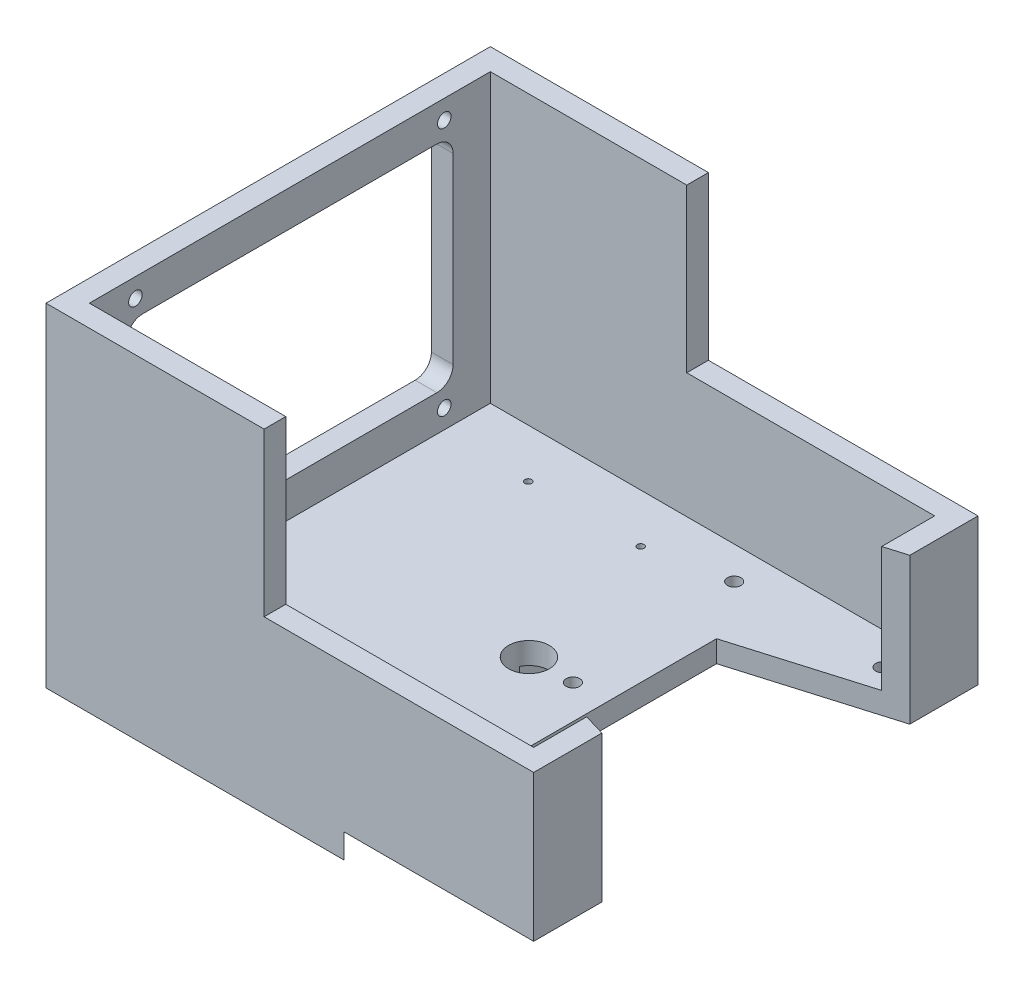
from build123d import *

# Parameters (mm, degrees)
BOSS_EXTRUDE1_DEPTH = 8
BOSS_EXTRUDE2_DEPTH = 9
BOSS_EXTRUDE3_DEPTH = 106
CUT_EXTRUDE1_REACH  = 163.431
SKETCH4_R           = 2.5
SKETCH4_R_2         = 7.5
CUT_EXTRUDE2_REACH  = 163.431
SKETCH5_R           = 1.25
SKETCH7_W           = 99.5
SKETCH7_H           = 60
CUT_EXTRUDE3_DEPTH  = 220.070764823
CUT_EXTRUDE4_REACH  = 224.045


with BuildPart() as part:
    # Sketch1 → Boss-Extrude1 (new body)
    with BuildSketch(Plane(origin=(0, 0, 0), x_dir=(1, 0, 0), z_dir=(0, 1, 0))):
        Polygon((35, 40.5), (90, 56.816666667), (90, 82), (-90, 82), (-90, -82), (90, -82), (90, -56.816666667), (35, -40.5), align=None)
    extrude(amount=BOSS_EXTRUDE1_DEPTH)

    # Sketch2 → Boss-Extrude2 (add)
    with BuildSketch(Plane.XZ):
        with BuildLine():
            ThreePointArc((-0.5, 61.5), (5.504310986, 75.995689014), (20, 82))
            Line((20, 82), (-90, 82))
            Line((-90, 82), (-90, -82))
            Line((-90, -82), (20, -82))
            ThreePointArc((20, -82), (5.504310986, -75.995689014), (-0.5, -61.5))
            Line((-0.5, -61.5), (-0.5, 61.5))
        make_face()
    extrude(amount=BOSS_EXTRUDE2_DEPTH)

    # Sketch3 → Boss-Extrude3 (add)
    with BuildSketch(Plane(origin=(0, 8, 0), x_dir=(1, 0, 0), z_dir=(0, 1, 0))):
        Polygon((90, 82), (-90, 82), (-90, -82), (90, -82), (90, -56.816666667), (82, -54.443333333), (82, -62.787955021), (82, -74), (-82, -74), (-82, 74), (82, 74), (82, 62.787955021), (82, 54.443333333), (90, 56.816666667), align=None)
    extrude(amount=BOSS_EXTRUDE3_DEPTH)

    # Sketch4 → Cut-Extrude1 (cut, up to next)
    with BuildSketch(Plane(origin=(0, 8, 0), x_dir=(1, 0, 0), z_dir=(0, 1, 0)), mode=Mode.PRIVATE) as cut_extrude1_sk1:
        with Locations(Location((74.76, 62, 0), (0, 0, 270))):
            Circle(SKETCH4_R)
    cut_extrude1_tool1 = extrude(cut_extrude1_sk1.sketch, amount=-CUT_EXTRUDE1_REACH, mode=Mode.PRIVATE) & part.part
    # Sketch4 → Cut-Extrude1 (cut, up to next)
    with BuildSketch(Plane(origin=(0, 8, 0), x_dir=(1, 0, 0), z_dir=(0, 1, 0)), mode=Mode.PRIVATE) as cut_extrude1_sk2:
        with Locations(Location((6.25, 0, 0), (0, 0, 270))):
            Circle(SKETCH4_R_2)
    cut_extrude1_tool2 = extrude(cut_extrude1_sk2.sketch, amount=-CUT_EXTRUDE1_REACH, mode=Mode.PRIVATE) & part.part
    # Sketch4 → Cut-Extrude1 (cut, up to next)
    with BuildSketch(Plane(origin=(0, 8, 0), x_dir=(1, 0, 0), z_dir=(0, 1, 0)), mode=Mode.PRIVATE) as cut_extrude1_sk3:
        with Locations(Location((22.5, 0, 0), (0, 0, 270))):
            Circle(SKETCH4_R)
    cut_extrude1_tool3 = extrude(cut_extrude1_sk3.sketch, amount=-CUT_EXTRUDE1_REACH, mode=Mode.PRIVATE) & part.part
    # Sketch4 → Cut-Extrude1 (cut, up to next)
    with BuildSketch(Plane(origin=(0, 8, 0), x_dir=(1, 0, 0), z_dir=(0, 1, 0)), mode=Mode.PRIVATE) as cut_extrude1_sk4:
        with Locations(Location((20, 62, 0), (0, 0, 270))):
            Circle(SKETCH4_R)
    cut_extrude1_tool4 = extrude(cut_extrude1_sk4.sketch, amount=-CUT_EXTRUDE1_REACH, mode=Mode.PRIVATE) & part.part
    # Sketch4 → Cut-Extrude1 (cut, up to next)
    with BuildSketch(Plane(origin=(0, 8, 0), x_dir=(1, 0, 0), z_dir=(0, 1, 0)), mode=Mode.PRIVATE) as cut_extrude1_sk5:
        with Locations(Location((20, -62, 0), (0, 0, 270))):
            Circle(SKETCH4_R)
    cut_extrude1_tool5 = extrude(cut_extrude1_sk5.sketch, amount=-CUT_EXTRUDE1_REACH, mode=Mode.PRIVATE) & part.part
    # Sketch4 → Cut-Extrude1 (cut, up to next)
    with BuildSketch(Plane(origin=(0, 8, 0), x_dir=(1, 0, 0), z_dir=(0, 1, 0)), mode=Mode.PRIVATE) as cut_extrude1_sk6:
        with Locations(Location((74.76, -62, 0), (0, 0, 270))):
            Circle(SKETCH4_R)
    cut_extrude1_tool6 = extrude(cut_extrude1_sk6.sketch, amount=-CUT_EXTRUDE1_REACH, mode=Mode.PRIVATE) & part.part
    add(cut_extrude1_tool1.solids().sort_by_distance((74.76, 8, -62))[0], mode=Mode.SUBTRACT)
    add(cut_extrude1_tool2.solids().sort_by_distance((6.25, 8, 0))[0], mode=Mode.SUBTRACT)
    add(cut_extrude1_tool3.solids().sort_by_distance((22.5, 8, 0))[0], mode=Mode.SUBTRACT)
    add(cut_extrude1_tool4.solids().sort_by_distance((20, 8, -62))[0], mode=Mode.SUBTRACT)
    add(cut_extrude1_tool5.solids().sort_by_distance((20, 8, 62))[0], mode=Mode.SUBTRACT)
    add(cut_extrude1_tool6.solids().sort_by_distance((74.76, 8, 62))[0], mode=Mode.SUBTRACT)

    # Sketch5 → Cut-Extrude2 (cut, up to next)
    with BuildSketch(Plane(origin=(0, 8, 0), x_dir=(1, 0, 0), z_dir=(0, 1, 0)), mode=Mode.PRIVATE) as cut_extrude2_sk1:
        with Locations(Location((-50, 56, 0), (0, 0, 270))):
            Circle(SKETCH5_R)
    cut_extrude2_tool1 = extrude(cut_extrude2_sk1.sketch, amount=-CUT_EXTRUDE2_REACH, mode=Mode.PRIVATE) & part.part
    # Sketch5 → Cut-Extrude2 (cut, up to next)
    with BuildSketch(Plane(origin=(0, 8, 0), x_dir=(1, 0, 0), z_dir=(0, 1, 0)), mode=Mode.PRIVATE) as cut_extrude2_sk2:
        with Locations(Location((-8.5, 56, 0), (0, 0, 90))):
            Circle(SKETCH5_R)
    cut_extrude2_tool2 = extrude(cut_extrude2_sk2.sketch, amount=-CUT_EXTRUDE2_REACH, mode=Mode.PRIVATE) & part.part
    # Sketch5 → Cut-Extrude2 (cut, up to next)
    with BuildSketch(Plane(origin=(0, 8, 0), x_dir=(1, 0, 0), z_dir=(0, 1, 0)), mode=Mode.PRIVATE) as cut_extrude2_sk3:
        with Locations(Location((-8.5, -56, 0), (0, 0, 270))):
            Circle(SKETCH5_R)
    cut_extrude2_tool3 = extrude(cut_extrude2_sk3.sketch, amount=-CUT_EXTRUDE2_REACH, mode=Mode.PRIVATE) & part.part
    # Sketch5 → Cut-Extrude2 (cut, up to next)
    with BuildSketch(Plane(origin=(0, 8, 0), x_dir=(1, 0, 0), z_dir=(0, 1, 0)), mode=Mode.PRIVATE) as cut_extrude2_sk4:
        with Locations(Location((-50, -56, 0), (0, 0, 90))):
            Circle(SKETCH5_R)
    cut_extrude2_tool4 = extrude(cut_extrude2_sk4.sketch, amount=-CUT_EXTRUDE2_REACH, mode=Mode.PRIVATE) & part.part
    add(cut_extrude2_tool1.solids().sort_by_distance((-50, 8, -56))[0], mode=Mode.SUBTRACT)
    add(cut_extrude2_tool2.solids().sort_by_distance((-8.5, 8, -56))[0], mode=Mode.SUBTRACT)
    add(cut_extrude2_tool3.solids().sort_by_distance((-8.5, 8, 56))[0], mode=Mode.SUBTRACT)
    add(cut_extrude2_tool4.solids().sort_by_distance((-50, 8, 56))[0], mode=Mode.SUBTRACT)

    # Sketch7 → Cut-Extrude3 (cut, through all)
    with BuildSketch(Plane.XY.offset(82)):
        with Locations((40.25, 84)):
            Rectangle(SKETCH7_W, SKETCH7_H)
    extrude(amount=-CUT_EXTRUDE3_DEPTH, mode=Mode.SUBTRACT)

    # Sketch8 → Cut-Extrude4 (cut, up to next)
    with BuildSketch(Plane(origin=(-82, 0, 0), x_dir=(0, 0, -1), z_dir=(1, 0, 0)), mode=Mode.PRIVATE) as cut_extrude4_sk1:
        with BuildLine():
            Line((-57, 104.5), (-57, 107))
            Line((-57, 107), (-54.5, 107))
            ThreePointArc((-54.5, 107), (-58.767766953, 108.767766953), (-57, 104.5))
        make_face()
    cut_extrude4_tool1 = extrude(cut_extrude4_sk1.sketch, amount=-CUT_EXTRUDE4_REACH, mode=Mode.PRIVATE) & part.part
    # Sketch8 → Cut-Extrude4 (cut, up to next)
    with BuildSketch(Plane(origin=(-82, 0, 0), x_dir=(0, 0, -1), z_dir=(1, 0, 0)), mode=Mode.PRIVATE) as cut_extrude4_sk2:
        with BuildLine():
            Line((-54.5, 107), (-57, 107))
            Line((-57, 107), (-57, 104.5))
            ThreePointArc((-57, 104.5), (-55.232233047, 105.232233047), (-54.5, 107))
        make_face()
    cut_extrude4_tool2 = extrude(cut_extrude4_sk2.sketch, amount=-CUT_EXTRUDE4_REACH, mode=Mode.PRIVATE) & part.part
    # Sketch8 → Cut-Extrude4 (cut, up to next)
    with BuildSketch(Plane(origin=(-82, 0, 0), x_dir=(0, 0, -1), z_dir=(1, 0, 0)), mode=Mode.PRIVATE) as cut_extrude4_sk3:
        with BuildLine():
            Line((-57, 104.5), (-57, 107))
            Line((-57, 107), (-54.5, 107))
            ThreePointArc((-54.5, 107), (-58.767766953, 108.767766953), (-57, 104.5))
        make_face()
    cut_extrude4_tool3 = extrude(cut_extrude4_sk3.sketch, amount=-CUT_EXTRUDE4_REACH, mode=Mode.PRIVATE) & part.part
    # Sketch8 → Cut-Extrude4 (cut, up to next)
    with BuildSketch(Plane(origin=(-82, 0, 0), x_dir=(0, 0, -1), z_dir=(1, 0, 0)), mode=Mode.PRIVATE) as cut_extrude4_sk4:
        with BuildLine():
            Line((-54.5, 107), (-57, 107))
            Line((-57, 107), (-57, 104.5))
            ThreePointArc((-57, 104.5), (-55.232233047, 105.232233047), (-54.5, 107))
        make_face()
    cut_extrude4_tool4 = extrude(cut_extrude4_sk4.sketch, amount=-CUT_EXTRUDE4_REACH, mode=Mode.PRIVATE) & part.part
    # Sketch8 → Cut-Extrude4 (cut, up to next)
    with BuildSketch(Plane(origin=(-82, 0, 0), x_dir=(0, 0, -1), z_dir=(1, 0, 0)), mode=Mode.PRIVATE) as cut_extrude4_sk5:
        with BuildLine():
            ThreePointArc((59.5, 107), (57, 109.5), (54.5, 107))
            Line((54.5, 107), (57, 107))
            Line((57, 107), (57, 104.5))
            ThreePointArc((57, 104.5), (58.767766953, 105.232233047), (59.5, 107))
        make_face()
    cut_extrude4_tool5 = extrude(cut_extrude4_sk5.sketch, amount=-CUT_EXTRUDE4_REACH, mode=Mode.PRIVATE) & part.part
    # Sketch8 → Cut-Extrude4 (cut, up to next)
    with BuildSketch(Plane(origin=(-82, 0, 0), x_dir=(0, 0, -1), z_dir=(1, 0, 0)), mode=Mode.PRIVATE) as cut_extrude4_sk6:
        with BuildLine():
            Line((57, 107), (54.5, 107))
            ThreePointArc((54.5, 107), (55.232233047, 105.232233047), (57, 104.5))
            Line((57, 104.5), (57, 107))
        make_face()
    cut_extrude4_tool6 = extrude(cut_extrude4_sk6.sketch, amount=-CUT_EXTRUDE4_REACH, mode=Mode.PRIVATE) & part.part
    # Sketch8 → Cut-Extrude4 (cut, up to next)
    with BuildSketch(Plane(origin=(-82, 0, 0), x_dir=(0, 0, -1), z_dir=(1, 0, 0)), mode=Mode.PRIVATE) as cut_extrude4_sk7:
        with BuildLine():
            ThreePointArc((59.5, 107), (57, 109.5), (54.5, 107))
            Line((54.5, 107), (57, 107))
            Line((57, 107), (57, 104.5))
            ThreePointArc((57, 104.5), (58.767766953, 105.232233047), (59.5, 107))
        make_face()
    cut_extrude4_tool7 = extrude(cut_extrude4_sk7.sketch, amount=-CUT_EXTRUDE4_REACH, mode=Mode.PRIVATE) & part.part
    # Sketch8 → Cut-Extrude4 (cut, up to next)
    with BuildSketch(Plane(origin=(-82, 0, 0), x_dir=(0, 0, -1), z_dir=(1, 0, 0)), mode=Mode.PRIVATE) as cut_extrude4_sk8:
        with BuildLine():
            Line((57, 107), (54.5, 107))
            ThreePointArc((54.5, 107), (55.232233047, 105.232233047), (57, 104.5))
            Line((57, 104.5), (57, 107))
        make_face()
    cut_extrude4_tool8 = extrude(cut_extrude4_sk8.sketch, amount=-CUT_EXTRUDE4_REACH, mode=Mode.PRIVATE) & part.part
    # Sketch8 → Cut-Extrude4 (cut, up to next)
    with BuildSketch(Plane(origin=(-82, 0, 0), x_dir=(0, 0, -1), z_dir=(1, 0, 0)), mode=Mode.PRIVATE) as cut_extrude4_sk9:
        with BuildLine():
            ThreePointArc((-54.5, 15), (-55.232233047, 16.767766953), (-57, 17.5))
            Line((-57, 17.5), (-57, 15))
            Line((-57, 15), (-54.5, 15))
        make_face()
    cut_extrude4_tool9 = extrude(cut_extrude4_sk9.sketch, amount=-CUT_EXTRUDE4_REACH, mode=Mode.PRIVATE) & part.part
    # Sketch8 → Cut-Extrude4 (cut, up to next)
    with BuildSketch(Plane(origin=(-82, 0, 0), x_dir=(0, 0, -1), z_dir=(1, 0, 0)), mode=Mode.PRIVATE) as cut_extrude4_sk10:
        with BuildLine():
            Line((-57, 15), (-57, 17.5))
            ThreePointArc((-57, 17.5), (-58.767766953, 13.232233047), (-54.5, 15))
            Line((-54.5, 15), (-57, 15))
        make_face()
    cut_extrude4_tool10 = extrude(cut_extrude4_sk10.sketch, amount=-CUT_EXTRUDE4_REACH, mode=Mode.PRIVATE) & part.part
    # Sketch8 → Cut-Extrude4 (cut, up to next)
    with BuildSketch(Plane(origin=(-82, 0, 0), x_dir=(0, 0, -1), z_dir=(1, 0, 0)), mode=Mode.PRIVATE) as cut_extrude4_sk11:
        with BuildLine():
            ThreePointArc((-54.5, 15), (-55.232233047, 16.767766953), (-57, 17.5))
            Line((-57, 17.5), (-57, 15))
            Line((-57, 15), (-54.5, 15))
        make_face()
    cut_extrude4_tool11 = extrude(cut_extrude4_sk11.sketch, amount=-CUT_EXTRUDE4_REACH, mode=Mode.PRIVATE) & part.part
    # Sketch8 → Cut-Extrude4 (cut, up to next)
    with BuildSketch(Plane(origin=(-82, 0, 0), x_dir=(0, 0, -1), z_dir=(1, 0, 0)), mode=Mode.PRIVATE) as cut_extrude4_sk12:
        with BuildLine():
            Line((-57, 15), (-57, 17.5))
            ThreePointArc((-57, 17.5), (-58.767766953, 13.232233047), (-54.5, 15))
            Line((-54.5, 15), (-57, 15))
        make_face()
    cut_extrude4_tool12 = extrude(cut_extrude4_sk12.sketch, amount=-CUT_EXTRUDE4_REACH, mode=Mode.PRIVATE) & part.part
    # Sketch8 → Cut-Extrude4 (cut, up to next)
    with BuildSketch(Plane(origin=(-82, 0, 0), x_dir=(0, 0, -1), z_dir=(1, 0, 0)), mode=Mode.PRIVATE) as cut_extrude4_sk13:
        with BuildLine():
            ThreePointArc((59.5, 15), (58.767766953, 16.767766953), (57, 17.5))
            Line((57, 17.5), (57, 15))
            Line((57, 15), (54.5, 15))
            ThreePointArc((54.5, 15), (57, 12.5), (59.5, 15))
        make_face()
    cut_extrude4_tool13 = extrude(cut_extrude4_sk13.sketch, amount=-CUT_EXTRUDE4_REACH, mode=Mode.PRIVATE) & part.part
    # Sketch8 → Cut-Extrude4 (cut, up to next)
    with BuildSketch(Plane(origin=(-82, 0, 0), x_dir=(0, 0, -1), z_dir=(1, 0, 0)), mode=Mode.PRIVATE) as cut_extrude4_sk14:
        with BuildLine():
            Line((57, 15), (57, 17.5))
            ThreePointArc((57, 17.5), (55.232233047, 16.767766953), (54.5, 15))
            Line((54.5, 15), (57, 15))
        make_face()
    cut_extrude4_tool14 = extrude(cut_extrude4_sk14.sketch, amount=-CUT_EXTRUDE4_REACH, mode=Mode.PRIVATE) & part.part
    # Sketch8 → Cut-Extrude4 (cut, up to next)
    with BuildSketch(Plane(origin=(-82, 0, 0), x_dir=(0, 0, -1), z_dir=(1, 0, 0)), mode=Mode.PRIVATE) as cut_extrude4_sk15:
        with BuildLine():
            ThreePointArc((59.5, 15), (58.767766953, 16.767766953), (57, 17.5))
            Line((57, 17.5), (57, 15))
            Line((57, 15), (54.5, 15))
            ThreePointArc((54.5, 15), (57, 12.5), (59.5, 15))
        make_face()
    cut_extrude4_tool15 = extrude(cut_extrude4_sk15.sketch, amount=-CUT_EXTRUDE4_REACH, mode=Mode.PRIVATE) & part.part
    # Sketch8 → Cut-Extrude4 (cut, up to next)
    with BuildSketch(Plane(origin=(-82, 0, 0), x_dir=(0, 0, -1), z_dir=(1, 0, 0)), mode=Mode.PRIVATE) as cut_extrude4_sk16:
        with BuildLine():
            Line((57, 15), (57, 17.5))
            ThreePointArc((57, 17.5), (55.232233047, 16.767766953), (54.5, 15))
            Line((54.5, 15), (57, 15))
        make_face()
    cut_extrude4_tool16 = extrude(cut_extrude4_sk16.sketch, amount=-CUT_EXTRUDE4_REACH, mode=Mode.PRIVATE) & part.part
    # Sketch8 → Cut-Extrude4 (cut, up to next)
    with BuildSketch(Plane(origin=(-82, 0, 0), x_dir=(0, 0, -1), z_dir=(1, 0, 0)), mode=Mode.PRIVATE) as cut_extrude4_sk17:
        with BuildLine():
            Line((-60.25, 94.75), (-60.25, 27.25))
            ThreePointArc((-60.25, 27.25), (-58.492640687, 23.007359313), (-54.25, 21.25))
            Line((-54.25, 21.25), (54.25, 21.25))
            ThreePointArc((54.25, 21.25), (58.492640687, 23.007359313), (60.25, 27.25))
            Line((60.25, 27.25), (60.25, 94.75))
            ThreePointArc((60.25, 94.75), (58.492640687, 98.992640687), (54.25, 100.75))
            Line((54.25, 100.75), (-54.25, 100.75))
            ThreePointArc((-54.25, 100.75), (-58.492640687, 98.992640687), (-60.25, 94.75))
        make_face()
    cut_extrude4_tool17 = extrude(cut_extrude4_sk17.sketch, amount=-CUT_EXTRUDE4_REACH, mode=Mode.PRIVATE) & part.part
    add(cut_extrude4_tool1.solids().sort_by_distance((-82, 107.353678, 57.353678))[0], mode=Mode.SUBTRACT)
    add(cut_extrude4_tool2.solids().sort_by_distance((-82, 105.938967, 55.938967))[0], mode=Mode.SUBTRACT)
    add(cut_extrude4_tool3.solids().sort_by_distance((-82, 107.353678, 57.353678))[0], mode=Mode.SUBTRACT)
    add(cut_extrude4_tool4.solids().sort_by_distance((-82, 105.938967, 55.938967))[0], mode=Mode.SUBTRACT)
    add(cut_extrude4_tool5.solids().sort_by_distance((-82, 107.353678, -57.353678))[0], mode=Mode.SUBTRACT)
    add(cut_extrude4_tool6.solids().sort_by_distance((-82, 105.938967, -55.938967))[0], mode=Mode.SUBTRACT)
    add(cut_extrude4_tool7.solids().sort_by_distance((-82, 107.353678, -57.353678))[0], mode=Mode.SUBTRACT)
    add(cut_extrude4_tool8.solids().sort_by_distance((-82, 105.938967, -55.938967))[0], mode=Mode.SUBTRACT)
    add(cut_extrude4_tool9.solids().sort_by_distance((-82, 16.061033, 55.938967))[0], mode=Mode.SUBTRACT)
    add(cut_extrude4_tool10.solids().sort_by_distance((-82, 14.646322, 57.353678))[0], mode=Mode.SUBTRACT)
    add(cut_extrude4_tool11.solids().sort_by_distance((-82, 16.061033, 55.938967))[0], mode=Mode.SUBTRACT)
    add(cut_extrude4_tool12.solids().sort_by_distance((-82, 14.646322, 57.353678))[0], mode=Mode.SUBTRACT)
    add(cut_extrude4_tool13.solids().sort_by_distance((-82, 14.646322, -57.353678))[0], mode=Mode.SUBTRACT)
    add(cut_extrude4_tool14.solids().sort_by_distance((-82, 16.061033, -55.938967))[0], mode=Mode.SUBTRACT)
    add(cut_extrude4_tool15.solids().sort_by_distance((-82, 14.646322, -57.353678))[0], mode=Mode.SUBTRACT)
    add(cut_extrude4_tool16.solids().sort_by_distance((-82, 16.061033, -55.938967))[0], mode=Mode.SUBTRACT)
    add(cut_extrude4_tool17.solids().sort_by_distance((-82, 61, 0))[0], mode=Mode.SUBTRACT)


solid = part.part
